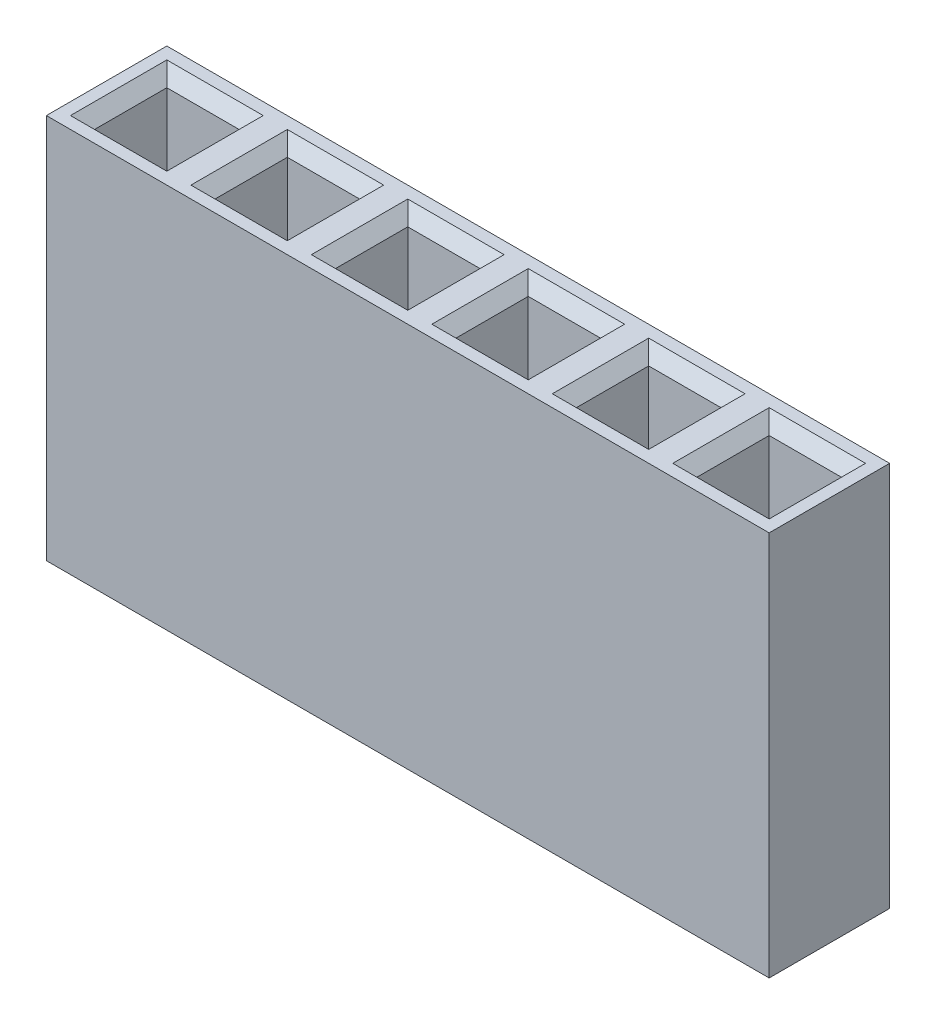
from build123d import *

# Parameters (mm, degrees)
SKETCH1_W                  = 2.5
SKETCH1_H                  = 8
BOSS_EXTRUDE1_DEPTH        = 2.5
SKETCH2_W                  = 1.5
SKETCH2_H                  = 1.5
CUT_EXTRUDE2_DEPTH         = 7
CHAMFER3_SIZE              = 0.25
LPATTERN2_COUNT            = 6
LPATTERN2_PITCH            = 2.5
CHAMFER3_OF_LPATTERN2_SIZE = 0.25


with BuildPart() as part:
    # Sketch1 → Boss-Extrude1 (new body)
    with BuildSketch(Plane.XY):
        Rectangle(SKETCH1_W, SKETCH1_H)
    boss_extrude1 = extrude(amount=BOSS_EXTRUDE1_DEPTH)

    # Sketch2 → Cut-Extrude2 (cut)
    with BuildSketch(Plane(origin=(0, 4, 0), x_dir=(1, 0, 0), z_dir=(0, 1, 0))):
        with Locations((0, -1.25)):
            Rectangle(SKETCH2_W, SKETCH2_H)
    cut_extrude2 = extrude(amount=-CUT_EXTRUDE2_DEPTH, mode=Mode.SUBTRACT)

    # Chamfer3
    chamfer3_edges = [part.edges().sort_by_distance(p)[0] for p in [
        (0, 4, 2),
        (0.75, 4, 1.25),
        (0, 4, 0.5),
        (-0.75, 4, 1.25),
    ]]
    chamfer(chamfer3_edges, length=CHAMFER3_SIZE)

    # LPattern2: Boss-Extrude1, Cut-Extrude2 ×6
    with Locations(*[(i * LPATTERN2_PITCH, 0, 0) for i in range(1, LPATTERN2_COUNT)]):
        add(boss_extrude1)
        add(cut_extrude2, mode=Mode.SUBTRACT)

    # Chamfer3 of LPattern2
    chamfer3_of_lpattern2_edges = [part.edges().sort_by_distance(p)[0] for p in [
        (2.5, 4, 2),
        (3.25, 4, 1.25),
        (2.5, 4, 0.5),
        (1.75, 4, 1.25),
        (5, 4, 2),
        (5.75, 4, 1.25),
        (5, 4, 0.5),
        (4.25, 4, 1.25),
        (7.5, 4, 2),
        (8.25, 4, 1.25),
        (7.5, 4, 0.5),
        (6.75, 4, 1.25),
        (10, 4, 2),
        (10.75, 4, 1.25),
        (10, 4, 0.5),
        (9.25, 4, 1.25),
        (12.5, 4, 2),
        (13.25, 4, 1.25),
        (12.5, 4, 0.5),
        (11.75, 4, 1.25),
    ]]
    chamfer(chamfer3_of_lpattern2_edges, length=CHAMFER3_OF_LPATTERN2_SIZE)


solid = part.part
